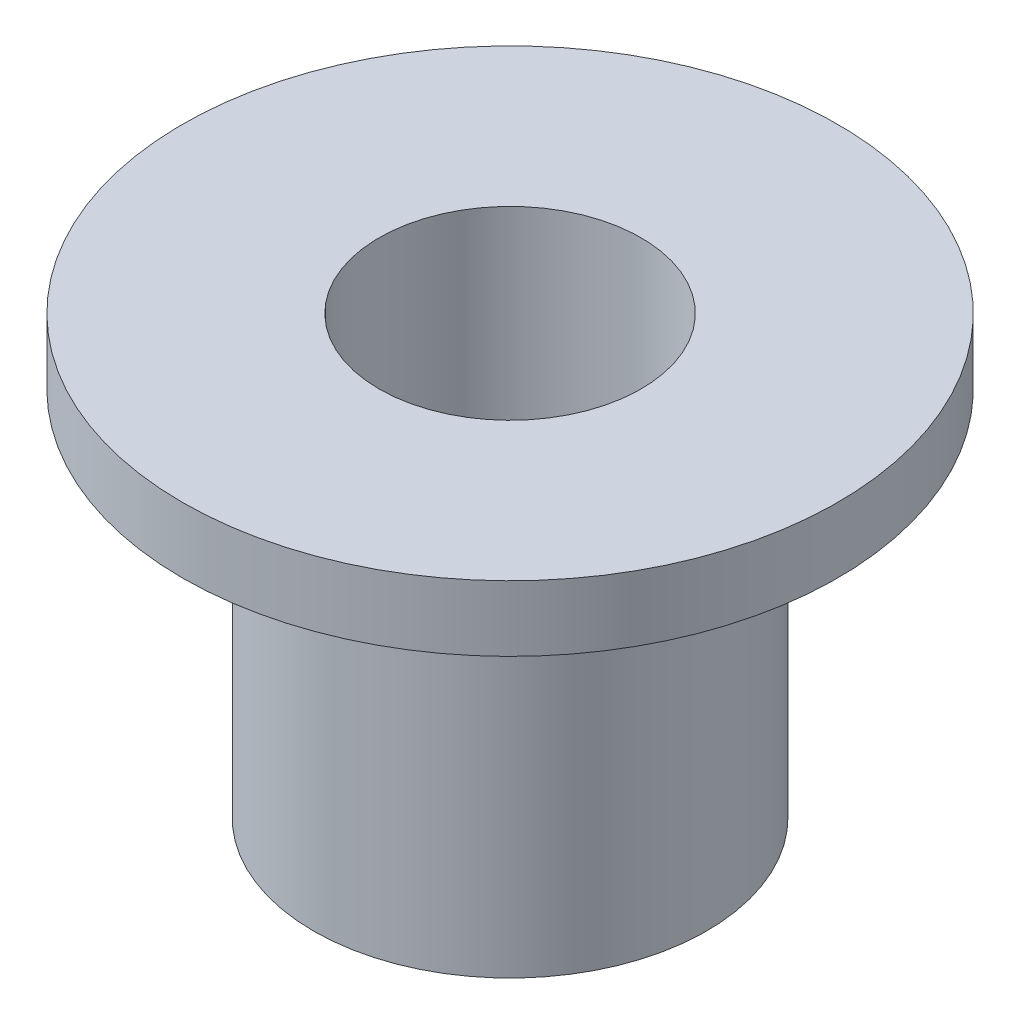
from build123d import *

# Parameters (mm, degrees)
SKETCH1_R           = 3.75
SKETCH1_R_2         = 1.5
BOSS_EXTRUDE1_DEPTH = 0.75
SKETCH2_R           = 2.25
SKETCH2_R_2         = 1.5
BOSS_EXTRUDE2_DEPTH = 5


with BuildPart() as part:
    # Sketch1 → Boss-Extrude1 (new body)
    with BuildSketch(Plane(origin=(0, 0, 0), x_dir=(1, 0, 0), z_dir=(0, 1, 0))):
        Circle(SKETCH1_R)
        Circle(SKETCH1_R_2, mode=Mode.SUBTRACT)
    extrude(amount=BOSS_EXTRUDE1_DEPTH)

    # Sketch2 → Boss-Extrude2 (add)
    with BuildSketch(Plane(origin=(0, 0.75, 0), x_dir=(1, 0, 0), z_dir=(0, 1, 0))):
        Circle(SKETCH2_R)
        Circle(SKETCH2_R_2, mode=Mode.SUBTRACT)
    extrude(amount=-BOSS_EXTRUDE2_DEPTH)


solid = part.part
